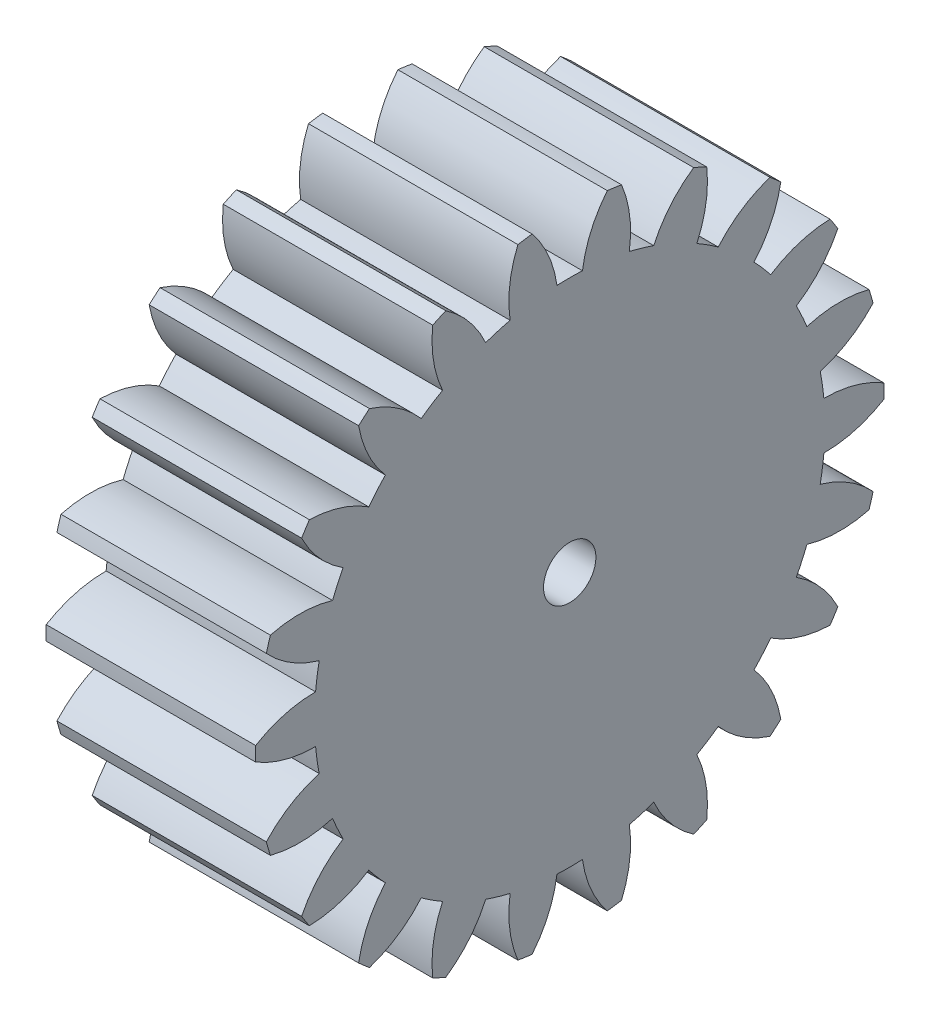
from build123d import *

# Parameters (mm, degrees)
BASPROSKE_W     = 20
BASPROSKE_H     = 30
TOOTHCUT_DEPTH  = 47.904157598
TEETHCUTS_COUNT = 22
TEETHCUTS_ANGLE = 343.636363636
BORSKE_R        = 2.5
BORE_DEPTH      = 50.0000508


with BuildPart() as part:
    # BasProSke → Base-Revolve (revolve)
    with BuildSketch(Plane(origin=(0, 0, 0), x_dir=(1, 0, 0), z_dir=(0, 1, 0)), mode=Mode.PRIVATE) as base_revolve_sk:
        with Locations((10, 15)):
            Rectangle(BASPROSKE_W, BASPROSKE_H)
    revolve(base_revolve_sk.sketch.rotate(Axis((-10, 0, 0), (1, 0, 0)), 180), axis=Axis((-10, 0, 0), (1, 0, 0)))

    # TooCutSke → ToothCut (cut, through all)
    with BuildSketch(Plane(origin=(0, 0, 0), x_dir=(0, 0, -1), z_dir=(1, 0, 0))):
        with BuildLine():
            ThreePointArc((1.215293185, 24.343683749), (0, 24.374), (-1.215293185, 24.343683749))
            ThreePointArc((-1.215293185, 24.343683749), (-2.034367134, 27.241050063), (-3.608361155, 29.807790507))
            ThreePointArc((-3.608361155, 29.807790507), (0, 30.0254), (3.608361155, 29.807790507))
            ThreePointArc((3.608361155, 29.807790507), (2.034367134, 27.241050063), (1.215293185, 24.343683749))
        make_face()
    toothcut = extrude(amount=TOOTHCUT_DEPTH, mode=Mode.SUBTRACT)

    # TeethCuts: ToothCut ×22 about axis
    teethcuts_axis = Axis((-10, 0, 0), (1, 0, 0))
    for i in range(1, TEETHCUTS_COUNT):
        add(toothcut.rotate(teethcuts_axis, i * TEETHCUTS_ANGLE / (TEETHCUTS_COUNT - 1)), mode=Mode.SUBTRACT)

    # BorSke → Bore (cut, symmetric)
    with BuildSketch(Plane(origin=(0, 0, 0), x_dir=(0, 0, -1), z_dir=(1, 0, 0))):
        with Locations(Location((0, 0, 0), (0, 0, 180))):
            Circle(BORSKE_R)
    extrude(amount=BORE_DEPTH, both=True, mode=Mode.SUBTRACT)


solid = part.part
